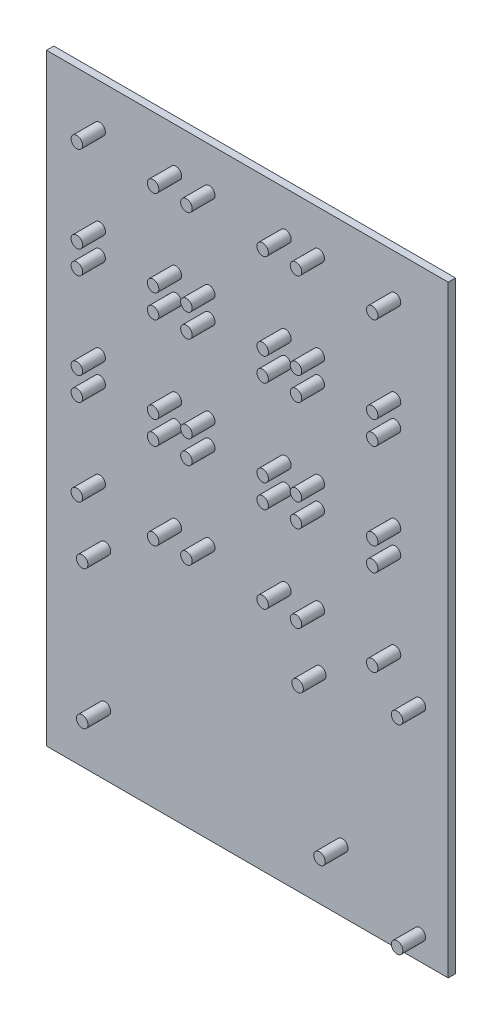
from build123d import *

# Parameters (mm, degrees)
SKETCH1_W           = 139.7
SKETCH1_H           = 209.55
BOSS_EXTRUDE1_DEPTH = 2.54
SKETCH2_R           = 2
BOSS_EXTRUDE2_DEPTH = 7.9375
SKETCH3_R           = 2
BOSS_EXTRUDE3_DEPTH = 7.9375


with BuildPart() as part:
    # Sketch1 → Boss-Extrude1 (new body)
    with BuildSketch(Plane.XY):
        Rectangle(SKETCH1_W, SKETCH1_H)
    extrude(amount=BOSS_EXTRUDE1_DEPTH)

    # Sketch2 → Boss-Extrude2 (add)
    with BuildSketch(Plane.XY.offset(2.54)):
        with Locations((-51.349999916, 14.125)):
            Circle(SKETCH2_R)
        with Locations((-24.849999916, 14.125)):
            Circle(SKETCH2_R)
        with Locations((-24.849999916, -15.875)):
            Circle(SKETCH2_R)
        with Locations((-51.349999916, -15.875)):
            Circle(SKETCH2_R)
        with Locations((13.250000084, 14.125)):
            Circle(SKETCH2_R)
        with Locations((-13.249999916, 14.125)):
            Circle(SKETCH2_R)
        with Locations((-13.249999916, -15.875)):
            Circle(SKETCH2_R)
        with Locations((13.250000084, -15.875)):
            Circle(SKETCH2_R)
        with Locations((51.350000084, 14.125)):
            Circle(SKETCH2_R)
        with Locations((24.850000084, 14.125)):
            Circle(SKETCH2_R)
        with Locations((24.850000084, -15.875)):
            Circle(SKETCH2_R)
        with Locations((51.350000084, -15.875)):
            Circle(SKETCH2_R)
        with Locations((13.250000084, 52.225)):
            Circle(SKETCH2_R)
        with Locations((-13.249999916, 52.225)):
            Circle(SKETCH2_R)
        with Locations((-13.249999916, 22.225)):
            Circle(SKETCH2_R)
        with Locations((13.250000084, 22.225)):
            Circle(SKETCH2_R)
        with Locations((51.350000084, 52.225)):
            Circle(SKETCH2_R)
        with Locations((24.850000084, 52.225)):
            Circle(SKETCH2_R)
        with Locations((24.850000084, 22.225)):
            Circle(SKETCH2_R)
        with Locations((51.350000084, 22.225)):
            Circle(SKETCH2_R)
        with Locations((13.250000084, 90.325)):
            Circle(SKETCH2_R)
        with Locations((-13.249999916, 90.325)):
            Circle(SKETCH2_R)
        with Locations((-13.249999916, 60.325)):
            Circle(SKETCH2_R)
        with Locations((13.250000084, 60.325)):
            Circle(SKETCH2_R)
        with Locations((51.350000084, 90.325)):
            Circle(SKETCH2_R)
        with Locations((24.850000084, 90.325)):
            Circle(SKETCH2_R)
        with Locations((24.850000084, 60.325)):
            Circle(SKETCH2_R)
        with Locations((51.350000084, 60.325)):
            Circle(SKETCH2_R)
        with Locations((-24.849999916, 52.225)):
            Circle(SKETCH2_R)
        with Locations((-51.349999916, 52.225)):
            Circle(SKETCH2_R)
        with Locations((-51.349999916, 22.225)):
            Circle(SKETCH2_R)
        with Locations((-24.849999916, 22.225)):
            Circle(SKETCH2_R)
        with Locations((-24.849999916, 90.325)):
            Circle(SKETCH2_R)
        with Locations((-51.349999916, 90.325)):
            Circle(SKETCH2_R)
        with Locations((-51.349999916, 60.325)):
            Circle(SKETCH2_R)
        with Locations((-24.849999916, 60.325)):
            Circle(SKETCH2_R)
    extrude(amount=BOSS_EXTRUDE2_DEPTH)

    # Sketch3 → Boss-Extrude3 (add)
    with BuildSketch(Plane.XY.offset(2.54)):
        with Locations((-49.5, -83.225)):
            Circle(SKETCH3_R)
        with Locations((33.02, -83.225)):
            Circle(SKETCH3_R)
        with Locations((60, -96.5125)):
            Circle(SKETCH3_R)
        with Locations((60, -27.3125)):
            Circle(SKETCH3_R)
        with Locations((25.4, -35.025)):
            Circle(SKETCH3_R)
        with Locations((-49.5, -35.025)):
            Circle(SKETCH3_R)
    extrude(amount=BOSS_EXTRUDE3_DEPTH)


solid = part.part
